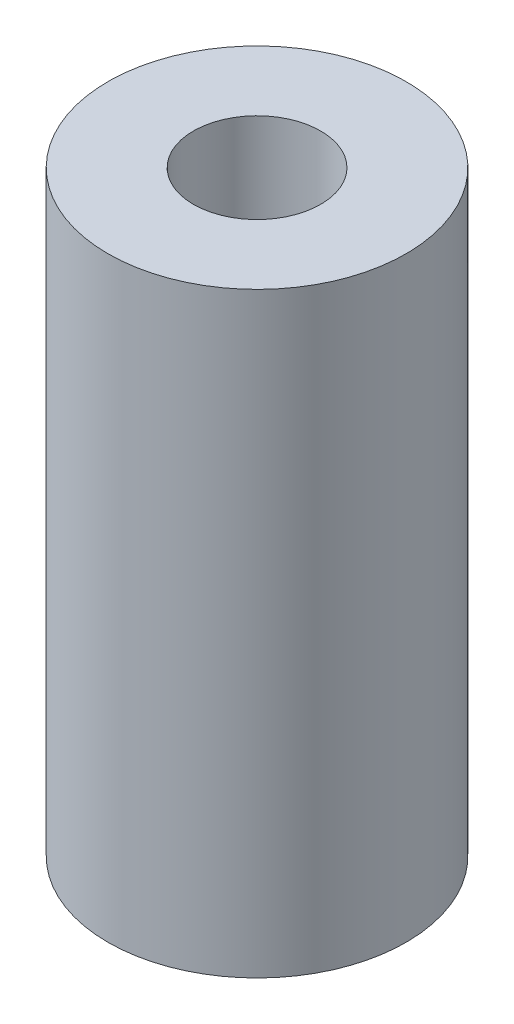
from build123d import *

# Parameters (mm, degrees)
SKETCH1_R           = 9.525
SKETCH1_R_2         = 4.064
BOSS_EXTRUDE1_DEPTH = 38.1


with BuildPart() as part:
    # Sketch1 → Boss-Extrude1 (new body)
    with BuildSketch(Plane(origin=(0, 0, 0), x_dir=(1, 0, 0), z_dir=(0, 1, 0))):
        Circle(SKETCH1_R)
        Circle(SKETCH1_R_2, mode=Mode.SUBTRACT)
    extrude(amount=BOSS_EXTRUDE1_DEPTH)


solid = part.part
